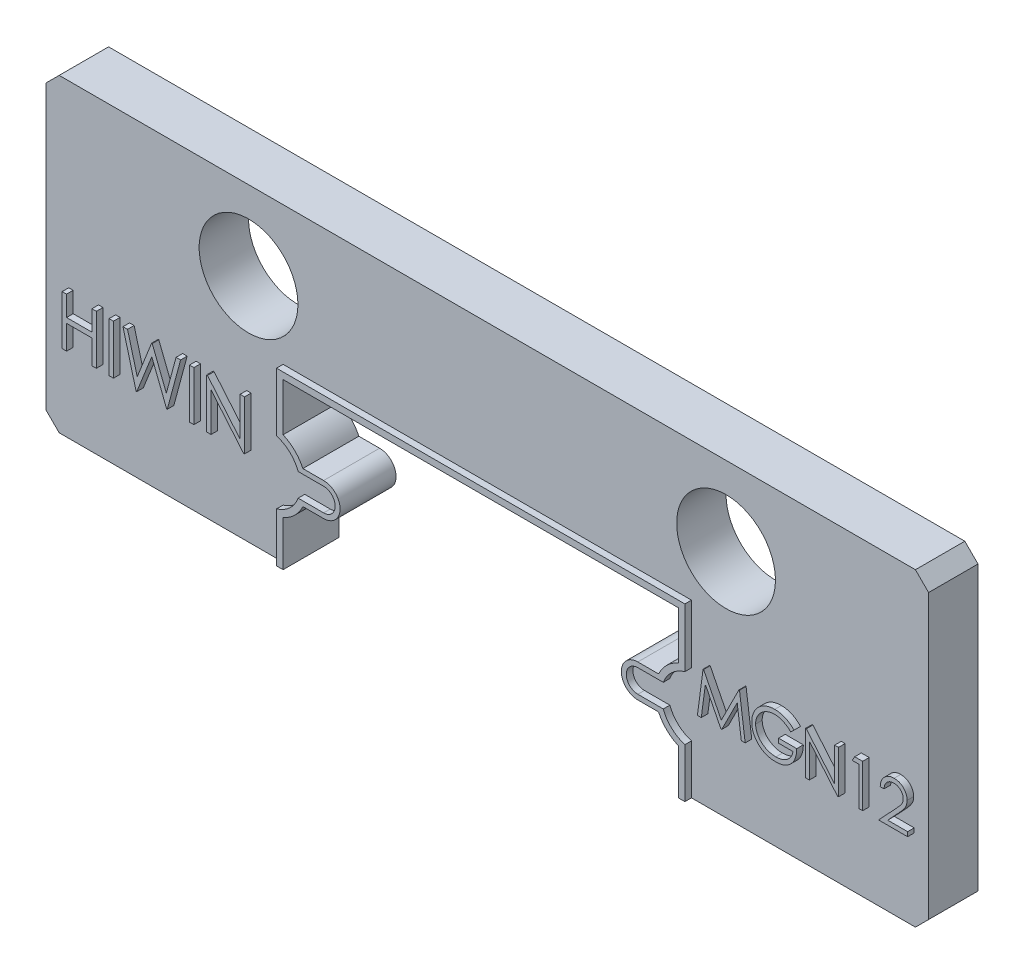
from build123d import *

# Parameters (mm, degrees)
BOSS_EXTRUDE1_DEPTH = 1.5
SKETCH2_R           = 1.5
CUT_EXTRUDE1_DEPTH  = 2.5
SKETCH3_W           = 0.134615385
SKETCH3_H           = 1.5
SKETCH3_W_2         = 0.134615384
BOSS_EXTRUDE2_DEPTH = 0.2
BOSS_EXTRUDE3_DEPTH = 0.2


with BuildPart() as part:
    # Sketch1 → Boss-Extrude1 (new body)
    with BuildSketch(Plane.XY):
        with BuildLine():
            Line((-6, -4.7), (-13, -4.7))
            Line((-13, -4.7), (-13.4, -4.3))
            Line((-13.4, -4.3), (-13.4, 4.3))
            Line((-13.4, 4.3), (-13, 4.7))
            Line((-13, 4.7), (13, 4.7))
            Line((13, 4.7), (13.4, 4.3))
            Line((13.4, 4.3), (13.4, -4.3))
            Line((13.4, -4.3), (13, -4.7))
            Line((13, -4.7), (6, -4.7))
            Line((6, -4.7), (6, -3.328898526))
            ThreePointArc((6, -3.328898526), (5.646338178, -3.089180762), (5.400138898, -2.74))
            Line((5.400138898, -2.74), (4.77, -2.74))
            ThreePointArc((4.77, -2.74), (4.27, -2.24), (4.77, -1.74))
            Line((4.77, -1.74), (5.400138898, -1.74))
            ThreePointArc((5.400138898, -1.74), (5.646338178, -1.390819238), (6, -1.151101474))
            Line((6, -1.151101474), (6, 0.3))
            Line((6, 0.3), (-6, 0.3))
            Line((-6, 0.3), (-6, -1.151101474))
            ThreePointArc((-6, -1.151101474), (-5.646338178, -1.390819238), (-5.400138898, -1.74))
            Line((-5.400138898, -1.74), (-4.77, -1.74))
            ThreePointArc((-4.77, -1.74), (-4.27, -2.24), (-4.77, -2.74))
            Line((-4.77, -2.74), (-5.400138898, -2.74))
            ThreePointArc((-5.400138898, -2.74), (-5.646338178, -3.089180762), (-6, -3.328898526))
            Line((-6, -3.328898526), (-6, -4.7))
        make_face()
    extrude(amount=-BOSS_EXTRUDE1_DEPTH)

    # Sketch2 → Cut-Extrude1 (cut, through all)
    with BuildSketch(Plane.XY):
        with Locations((-7.25, 2.3)):
            Circle(SKETCH2_R)
        with Locations((7.25, 2.3)):
            Circle(SKETCH2_R)
    extrude(amount=-CUT_EXTRUDE1_DEPTH, mode=Mode.SUBTRACT)

    # Sketch3 → Boss-Extrude2 (add)
    with BuildSketch(Plane.XY):
        Polygon((-8.324615385, -2.24), (-8.324615385, -0.74), (-8.296370192, -0.74), (-7.305384615, -1.920588942), (-7.305384615, -0.74), (-7.170769231, -0.74), (-7.170769231, -2.24), (-7.201418269, -2.24), (-8.19, -1.062115385), (-8.19, -2.24), align=None)
        with Locations((-8.776538462, -1.49)):
            Rectangle(SKETCH3_W, SKETCH3_H)
        Polygon((-10.863076923, -0.74), (-10.723954327, -0.74), (-10.430384615, -1.840060096), (-9.993786058, -0.74), (-9.974254808, -0.74), (-9.545769231, -1.832548077), (-9.250697115, -0.74), (-9.113076923, -0.74), (-9.517524038, -2.24), (-9.536754808, -2.24), (-9.988076923, -1.092764423), (-10.444807692, -2.24), (-10.464038462, -2.24), align=None)
        with Locations((-11.218846154, -1.49)):
            Rectangle(SKETCH3_W_2, SKETCH3_H)
        Polygon((-12.709230769, -0.74), (-12.574615385, -0.74), (-12.574615385, -1.355384615), (-11.805384615, -1.355384615), (-11.805384615, -0.74), (-11.670769231, -0.74), (-11.670769231, -2.24), (-11.805384615, -2.24), (-11.805384615, -1.509230769), (-12.574615385, -1.509230769), (-12.574615385, -2.24), (-12.709230769, -2.24), align=None)
        Polygon((6.58, -2.24), (6.751614583, -0.94), (6.76828125, -0.94), (7.305, -2.006666667), (7.840416667, -0.94), (7.85734375, -0.94), (8.03, -2.24), (7.9128125, -2.24), (7.788333333, -1.304583333), (7.3190625, -2.24), (7.292760417, -2.24), (6.821666667, -1.3025), (6.697447917, -2.24), align=None)
        with BuildLine():
            Line((9.513333333, -1.161875), (9.413333333, -1.256666667))
            add(Edge.make_bspline(
                [(9.413333333, -1.256666667), (9.395237746, -1.239643775), (9.359478072, -1.206003911), (9.301178553, -1.16235697), (9.240352061, -1.124966704), (9.17731599, -1.094544388), (9.113631385, -1.070270506), (9.050143553, -1.052988625), (8.987503721, -1.041967397), (8.945841612, -1.040649431), (8.9253125, -1.04)],
                knots=[0, 0, 0, 0, 7.4485e-05, 0.000147193, 0.000218028, 0.000288376, 0.000356864, 0.000422186, 0.000485548, 0.0005471, 0.0005471, 0.0005471, 0.0005471], degree=3))
            add(Edge.make_bspline(
                [(8.9253125, -1.04), (8.912715611, -1.040153625), (8.887554505, -1.040460477), (8.85018064, -1.0443769), (8.813198746, -1.050009563), (8.776678636, -1.058159404), (8.740549301, -1.068488483), (8.704936398, -1.081408798), (8.669773495, -1.096472174), (8.635391807, -1.113878236), (8.60205962, -1.132999322), (8.57057851, -1.15418878), (8.540747819, -1.176767473), (8.513128232, -1.201300694), (8.487560877, -1.227566215), (8.463437196, -1.255075443), (8.441605629, -1.284579953), (8.421886054, -1.3155369), (8.404294596, -1.34740257), (8.388765667, -1.379870252), (8.375729606, -1.412832255), (8.365415237, -1.446329941), (8.356905565, -1.48010416), (8.350919025, -1.514388771), (8.347543957, -1.549220482), (8.346960153, -1.572545178), (8.346666667, -1.584270833)],
                knots=[0, 0, 0, 0, 3.7775e-05, 7.5452e-05, 0.000112615, 0.000149956, 0.000187623, 0.000225268, 0.000263532, 0.000302314, 0.000340817, 0.000378736, 0.000416081, 0.000452975, 0.000489438, 0.000525989, 0.000562656, 0.000599426, 0.000636027, 0.000671787, 0.000707331, 0.000742254, 0.000776866, 0.000811759, 0.000846559, 0.00088174, 0.00088174, 0.00088174, 0.00088174], degree=3))
            add(Edge.make_bspline(
                [(8.346666667, -1.584270833), (8.346947362, -1.596257137), (8.347507986, -1.620197013), (8.351096105, -1.65592624), (8.357755166, -1.691124818), (8.366657458, -1.725908411), (8.377793189, -1.760336588), (8.391674465, -1.794260092), (8.408115974, -1.827677666), (8.427146693, -1.860288209), (8.448015854, -1.892053904), (8.471394713, -1.921976012), (8.496228644, -1.950452986), (8.523422378, -1.976852556), (8.552103923, -2.00188086), (8.583130197, -2.02484834), (8.61589111, -2.046197394), (8.650436646, -2.065658958), (8.686391965, -2.083044986), (8.723258759, -2.09850529), (8.761154805, -2.111237615), (8.799880947, -2.121614625), (8.839391019, -2.13012045), (8.879885575, -2.135592514), (8.921066866, -2.139563394), (8.94882693, -2.139853729), (8.9628125, -2.14)],
                knots=[0, 0, 0, 0, 3.5961e-05, 7.1824e-05, 0.000107578, 0.000143327, 0.00017948, 0.00021604, 0.000253192, 0.000291113, 0.000329249, 0.000367118, 0.000404943, 0.00044251, 0.000480727, 0.000519061, 0.00055821, 0.000597973, 0.000637922, 0.000677966, 0.000717824, 0.000757749, 0.0007982, 0.000838969, 0.000880276, 0.000922216, 0.000922216, 0.000922216, 0.000922216], degree=3))
            add(Edge.make_bspline(
                [(8.9628125, -2.14), (8.979667315, -2.139647672), (9.012764482, -2.138955818), (9.061416589, -2.133569996), (9.108143444, -2.12515833), (9.152813748, -2.112839568), (9.195479384, -2.097126775), (9.236296762, -2.078185631), (9.274944521, -2.055289638), (9.311538843, -2.029447916), (9.345248655, -2.000656692), (9.375651615, -1.969588752), (9.402262797, -1.936394898), (9.425478828, -1.901270638), (9.444684899, -1.863925239), (9.460449366, -1.824541716), (9.47253316, -1.783102354), (9.477493579, -1.75446832), (9.48, -1.74)],
                knots=[0, 0, 0, 0, 5.0554e-05, 9.927e-05, 0.000146671, 0.000192853, 0.000238086, 0.000282939, 0.000327646, 0.000372662, 0.000417178, 0.000460455, 0.000502874, 0.000544622, 0.000586552, 0.000628624, 0.000671728, 0.000715753, 0.000715753, 0.000715753, 0.000715753], degree=3))
            Line((9.48, -1.74), (9.046666667, -1.74))
            Line((9.046666667, -1.74), (9.046666667, -1.606666667))
            Line((9.046666667, -1.606666667), (9.596666667, -1.606666667))
            add(Edge.make_bspline(
                [(9.596666667, -1.606666667), (9.596033066, -1.63151802), (9.594792995, -1.680156607), (9.58609454, -1.751088421), (9.572048407, -1.818083622), (9.552860291, -1.881212763), (9.528020901, -1.940386383), (9.497796819, -1.995664562), (9.461704317, -2.046690186), (9.42102901, -2.093879816), (9.375380455, -2.135973523), (9.32599211, -2.172970015), (9.272782379, -2.204133843), (9.215801593, -2.229487804), (9.15523629, -2.249275287), (9.09094632, -2.26330473), (9.023018868, -2.271710145), (8.976465245, -2.272784086), (8.95265625, -2.273333333)],
                knots=[0, 0, 0, 0, 7.4545e-05, 0.000145897, 0.000214031, 0.000279683, 0.000343526, 0.00040623, 0.000468291, 0.000530688, 0.00059279, 0.000654197, 0.000715475, 0.000777374, 0.00084095, 0.000906283, 0.000974503, 0.001045914, 0.001045914, 0.001045914, 0.001045914], degree=3))
            add(Edge.make_bspline(
                [(8.95265625, -2.273333333), (8.937981057, -2.273121945), (8.909036846, -2.27270502), (8.866288787, -2.269742006), (8.824719385, -2.265180649), (8.784334696, -2.25829246), (8.744986169, -2.249855588), (8.706870323, -2.23905195), (8.669841962, -2.226546433), (8.633843853, -2.212322326), (8.599202736, -2.195841425), (8.565764315, -2.177526416), (8.533343754, -2.157471739), (8.502161893, -2.135330568), (8.472056262, -2.111268511), (8.443220983, -2.085237341), (8.415494628, -2.05731664), (8.398126456, -2.03749015), (8.389375, -2.0275)],
                knots=[0, 0, 0, 0, 4.4023e-05, 8.6827e-05, 0.000128498, 0.000169426, 0.000209677, 0.000249169, 0.000288204, 0.00032689, 0.000365215, 0.000403207, 0.000441218, 0.000479514, 0.000517866, 0.000556772, 0.000595995, 0.000635831, 0.000635831, 0.000635831, 0.000635831], degree=3))
            add(Edge.make_bspline(
                [(8.389375, -2.0275), (8.376677368, -2.0116509), (8.351492872, -1.98021578), (8.319075271, -1.929850086), (8.291440464, -1.877700824), (8.26901813, -1.823622819), (8.251509698, -1.767666654), (8.23895309, -1.709903832), (8.231596097, -1.650259969), (8.230536212, -1.609898585), (8.23, -1.589479167)],
                knots=[0, 0, 0, 0, 6.0892e-05, 0.000120773, 0.000179367, 0.000237741, 0.000296137, 0.000355031, 0.000414852, 0.000476106, 0.000476106, 0.000476106, 0.000476106], degree=3))
            add(Edge.make_bspline(
                [(8.23, -1.589479167), (8.230197688, -1.574188844), (8.230590553, -1.54380253), (8.235354316, -1.498689816), (8.242189128, -1.45437813), (8.252235177, -1.410903695), (8.264899504, -1.368237475), (8.280705085, -1.32635966), (8.299107475, -1.285245536), (8.320496373, -1.2451781), (8.344299172, -1.206689032), (8.370132111, -1.169933276), (8.39836202, -1.135580195), (8.428527888, -1.103194726), (8.460989628, -1.073183726), (8.495443128, -1.045269342), (8.531914941, -1.01941413), (8.570519808, -0.996025334), (8.610681519, -0.975015989), (8.652303805, -0.956597139), (8.695373961, -0.941374765), (8.73956931, -0.92845879), (8.785224381, -0.918907452), (8.832007867, -0.911980775), (8.880163622, -0.907241123), (8.912714148, -0.906859943), (8.92921875, -0.906666667)],
                knots=[0, 0, 0, 0, 4.5852e-05, 9.1121e-05, 0.000135947, 0.000180294, 0.000224868, 0.000269368, 0.000314477, 0.000359912, 0.000405515, 0.000450168, 0.000494582, 0.000538801, 0.000582842, 0.000627092, 0.000671745, 0.000716854, 0.000762398, 0.000807639, 0.000853272, 0.000899345, 0.000945671, 0.00099307, 0.001041191, 0.001090687, 0.001090687, 0.001090687, 0.001090687], degree=3))
            add(Edge.make_bspline(
                [(8.92921875, -0.906666667), (8.942678669, -0.906881906), (8.969368107, -0.907308702), (9.009083379, -0.910267), (9.048184784, -0.91495587), (9.086730301, -0.92135439), (9.124588665, -0.930069475), (9.161867727, -0.940498553), (9.198621526, -0.95264123), (9.234734876, -0.967122801), (9.270450599, -0.983559862), (9.305967283, -1.00206199), (9.341163574, -1.022945563), (9.37610051, -1.046272591), (9.4109984, -1.071642432), (9.445305267, -1.09978068), (9.479849218, -1.129577704), (9.50206132, -1.151002515), (9.513333333, -1.161875)],
                knots=[0, 0, 0, 0, 4.0378e-05, 8.0065e-05, 0.000119408, 0.000158495, 0.000197221, 0.00023589, 0.000274595, 0.000313282, 0.00035255, 0.000392503, 0.000433368, 0.00047526, 0.000518492, 0.000562742, 0.000608333, 0.000655307, 0.000655307, 0.000655307, 0.000655307], degree=3))
        make_face()
        Polygon((9.863333333, -2.24), (9.863333333, -0.94), (9.8878125, -0.94), (10.746666667, -1.963177083), (10.746666667, -0.94), (10.863333333, -0.94), (10.863333333, -2.24), (10.836770833, -2.24), (9.98, -1.219166667), (9.98, -2.24), align=None)
        Polygon((11.356302083, -0.94), (11.596666667, -0.94), (11.596666667, -2.24), (11.48, -2.24), (11.48, -1.073333333), (11.28, -1.073333333), align=None)
        with BuildLine():
            Line((12.246666667, -1.34), (12.13, -1.34))
            add(Edge.make_bspline(
                [(12.13, -1.34), (12.130760371, -1.324522242), (12.13225372, -1.294124336), (12.139247084, -1.249804028), (12.149253696, -1.207440817), (12.16340195, -1.167374849), (12.180972853, -1.129251864), (12.202044006, -1.093223286), (12.227001722, -1.059426559), (12.255307081, -1.028174989), (12.286049718, -0.99950532), (12.319220496, -0.974747658), (12.35407722, -0.953829666), (12.39051414, -0.936342347), (12.428942349, -0.923216119), (12.469013125, -0.913476653), (12.510902518, -0.907616867), (12.539443098, -0.906987004), (12.553958333, -0.906666667)],
                knots=[0, 0, 0, 0, 4.6459e-05, 9.1245e-05, 0.000134385, 0.000176883, 0.000218479, 0.00026015, 0.000301871, 0.000344281, 0.000386482, 0.000427784, 0.000468203, 0.000508274, 0.000548793, 0.000589786, 0.000631844, 0.000675372, 0.000675372, 0.000675372, 0.000675372], degree=3))
            add(Edge.make_bspline(
                [(12.553958333, -0.906666667), (12.568213047, -0.907000379), (12.596223049, -0.907656112), (12.637103226, -0.913287351), (12.676020506, -0.922107143), (12.71289882, -0.93448144), (12.747443929, -0.951115656), (12.779915346, -0.971097599), (12.810699647, -0.994207822), (12.838410738, -1.021416381), (12.863856596, -1.050462981), (12.885808862, -1.081472774), (12.904608037, -1.113500794), (12.920277747, -1.146791269), (12.931812884, -1.181657651), (12.940570505, -1.217592327), (12.945520687, -1.254967256), (12.946280415, -1.280263977), (12.946666667, -1.293125)],
                knots=[0, 0, 0, 0, 4.2747e-05, 8.3997e-05, 0.000123542, 0.00016233, 0.00020042, 0.000238294, 0.000276576, 0.000315621, 0.000354574, 0.000392294, 0.000429409, 0.000465877, 0.000502441, 0.000539392, 0.0005767, 0.000615285, 0.000615285, 0.000615285, 0.000615285], degree=3))
            add(Edge.make_bspline(
                [(12.946666667, -1.293125), (12.94603774, -1.311231339), (12.944790925, -1.347126275), (12.934125585, -1.399874653), (12.917468309, -1.45098078), (12.897412148, -1.492111778), (12.877179526, -1.525255647), (12.858947023, -1.552544023), (12.837602951, -1.581926054), (12.812836651, -1.613303351), (12.785160442, -1.646921687), (12.754323638, -1.682760754), (12.720106345, -1.720450268), (12.69609033, -1.746192349), (12.683645833, -1.75953125)],
                knots=[0, 0, 0, 0, 5.4272e-05, 0.000107592, 0.000160791, 0.000215183, 0.000244392, 0.000277255, 0.000313614, 0.00035331, 0.000397157, 0.000444243, 0.000495132, 0.00054986, 0.00054986, 0.00054986, 0.00054986], degree=3))
            Line((12.683645833, -1.75953125), (12.358385417, -2.106666667))
            Line((12.358385417, -2.106666667), (12.963333333, -2.106666667))
            Line((12.963333333, -2.106666667), (12.963333333, -2.24))
            Line((12.963333333, -2.24), (12.08, -2.24))
            Line((12.08, -2.24), (12.584166667, -1.701979167))
            add(Edge.make_bspline(
                [(12.584166667, -1.701979167), (12.596441596, -1.68916551), (12.620019223, -1.664553098), (12.653367038, -1.628619998), (12.683318662, -1.595284455), (12.710067979, -1.564609451), (12.73303471, -1.536146297), (12.753415824, -1.510816836), (12.769745901, -1.48750804), (12.787468762, -1.460490098), (12.804633955, -1.427502666), (12.819384259, -1.387190152), (12.828378346, -1.345691459), (12.829457284, -1.317647845), (12.83, -1.303541667)],
                knots=[0, 0, 0, 0, 5.3233e-05, 0.000102249, 0.00014706, 0.000187678, 0.000224324, 0.00025678, 0.000285176, 0.000309664, 0.000353692, 0.000396365, 0.000438144, 0.000480429, 0.000480429, 0.000480429, 0.000480429], degree=3))
            add(Edge.make_bspline(
                [(12.83, -1.303541667), (12.829763867, -1.294671433), (12.829298495, -1.277189906), (12.82519135, -1.251559195), (12.81898459, -1.226835121), (12.810090637, -1.202941634), (12.798350991, -1.180118964), (12.784060879, -1.158339328), (12.767573141, -1.137283427), (12.748499812, -1.117540773), (12.727546962, -1.099459183), (12.705411955, -1.083441665), (12.681993345, -1.07005571), (12.657389871, -1.059082411), (12.631670125, -1.050474412), (12.604784363, -1.044509797), (12.576806871, -1.040764874), (12.557703001, -1.040258182), (12.54796875, -1.04)],
                knots=[0, 0, 0, 0, 2.6594e-05, 5.2412e-05, 7.7677e-05, 0.000102975, 0.000128714, 0.000154501, 0.000181018, 0.000208829, 0.000236708, 0.000263954, 0.000290667, 0.000317478, 0.000344654, 0.000371884, 0.000399986, 0.000429181, 0.000429181, 0.000429181, 0.000429181], degree=3))
            add(Edge.make_bspline(
                [(12.54796875, -1.04), (12.537802441, -1.040265583), (12.517837488, -1.040787145), (12.488524704, -1.044435563), (12.460561415, -1.050729733), (12.43387728, -1.059338212), (12.408427148, -1.070279958), (12.384334789, -1.083908321), (12.361654287, -1.100170761), (12.340343007, -1.118608682), (12.320707815, -1.139136648), (12.303456118, -1.162020349), (12.288382056, -1.18684196), (12.275230055, -1.213534508), (12.26454937, -1.242340197), (12.256387914, -1.273156773), (12.249929942, -1.305850429), (12.247772492, -1.328427747), (12.246666667, -1.34)],
                knots=[0, 0, 0, 0, 3.0497e-05, 5.989e-05, 8.8447e-05, 0.000116365, 0.000143892, 0.000171412, 0.000199233, 0.00022748, 0.000255847, 0.000284285, 0.000313271, 0.000342853, 0.000373424, 0.000405263, 0.00043841, 0.000473265, 0.000473265, 0.000473265, 0.000473265], degree=3))
        make_face()
    extrude(amount=BOSS_EXTRUDE2_DEPTH)

    # Sketch4 → Boss-Extrude3 (add)
    with BuildSketch(Plane.XY):
        with BuildLine():
            Line((-6.2, -4.7), (-6.2, -3.2))
            ThreePointArc((-6.2, -3.2), (-5.799452457, -2.972703925), (-5.5432503, -2.59))
            Line((-5.5432503, -2.59), (-4.77, -2.59))
            ThreePointArc((-4.77, -2.59), (-4.42, -2.24), (-4.77, -1.89))
            Line((-4.77, -1.89), (-5.5432503, -1.89))
            ThreePointArc((-5.5432503, -1.89), (-5.799452457, -1.507296075), (-6.2, -1.28))
            Line((-6.2, -1.28), (-6.2, 0.5))
            Line((-6.2, 0.5), (6.2, 0.5))
            Line((6.2, 0.5), (6.2, -1.28))
            ThreePointArc((6.2, -1.28), (5.799452457, -1.507296075), (5.5432503, -1.89))
            Line((5.5432503, -1.89), (4.77, -1.89))
            ThreePointArc((4.77, -1.89), (4.42, -2.24), (4.77, -2.59))
            Line((4.77, -2.59), (5.5432503, -2.59))
            ThreePointArc((5.5432503, -2.59), (5.799452457, -2.972703925), (6.2, -3.2))
            Line((6.2, -3.2), (6.2, -4.7))
            Line((6.2, -4.7), (6, -4.7))
            Line((6, -4.7), (6, -3.328898526))
            ThreePointArc((6, -3.328898526), (5.646338178, -3.089180762), (5.400138898, -2.74))
            Line((5.400138898, -2.74), (4.77, -2.74))
            ThreePointArc((4.77, -2.74), (4.27, -2.24), (4.77, -1.74))
            Line((4.77, -1.74), (5.400138898, -1.74))
            ThreePointArc((5.400138898, -1.74), (5.646338178, -1.390819238), (6, -1.151101474))
            Line((6, -1.151101474), (6, 0.3))
            Line((6, 0.3), (-6, 0.3))
            Line((-6, 0.3), (-6, -1.151101474))
            ThreePointArc((-6, -1.151101474), (-5.646338178, -1.390819238), (-5.400138898, -1.74))
            Line((-5.400138898, -1.74), (-4.77, -1.74))
            ThreePointArc((-4.77, -1.74), (-4.27, -2.24), (-4.77, -2.74))
            Line((-4.77, -2.74), (-5.400138898, -2.74))
            ThreePointArc((-5.400138898, -2.74), (-5.646338178, -3.089180762), (-6, -3.328898526))
            Line((-6, -3.328898526), (-6, -4.7))
            Line((-6, -4.7), (-6.2, -4.7))
        make_face()
    extrude(amount=BOSS_EXTRUDE3_DEPTH)


solid = part.part
